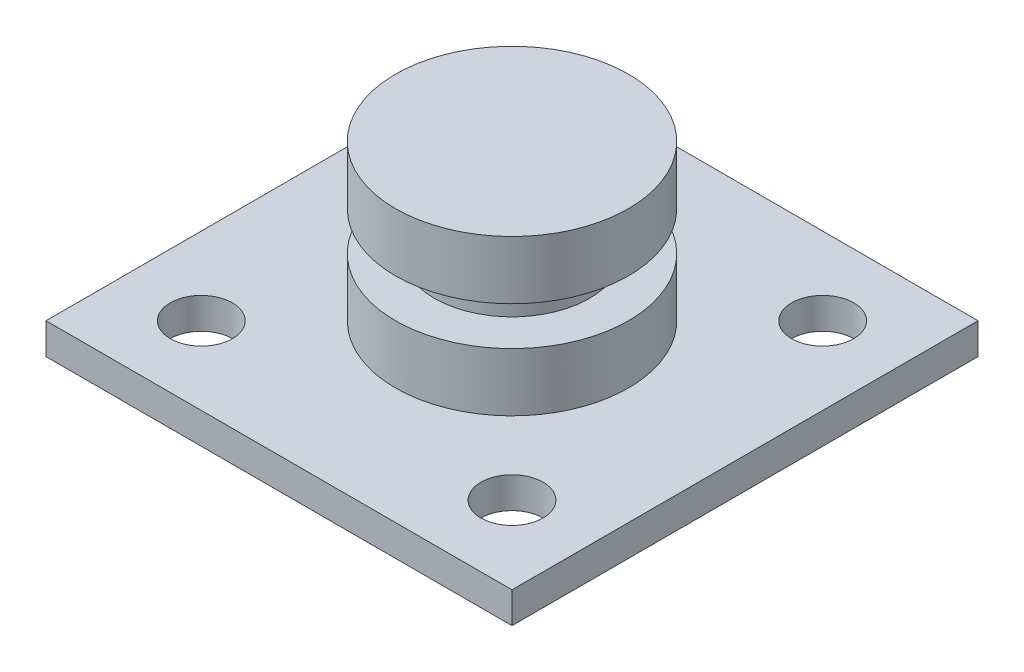
from build123d import *

# Parameters (mm, degrees)
SKETCH1_W           = 30
SKETCH1_H           = 30
BOSS_EXTRUDE1_DEPTH = 2
SKETCH3_R           = 2
CUT_EXTRUDE1_DEPTH  = 5
SKETCH2_R           = 7.5
BOSS_EXTRUDE2_DEPTH = 10
SKETCH4_W           = 5
SKETCH4_H           = 2.5


with BuildPart() as part:
    # Sketch1 → Boss-Extrude1 (new body)
    with BuildSketch(Plane(origin=(0, 0, 0), x_dir=(1, 0, 0), z_dir=(0, 1, 0))):
        Rectangle(SKETCH1_W, SKETCH1_H)
    extrude(amount=BOSS_EXTRUDE1_DEPTH)

    # Sketch3 → Cut-Extrude1 (cut)
    with BuildSketch(Plane(origin=(0, 2, 0), x_dir=(1, 0, 0), z_dir=(0, 1, 0))):
        with Locations((-10, 10)):
            Circle(SKETCH3_R)
        with Locations((10, 10)):
            Circle(SKETCH3_R)
        with Locations((10, -10)):
            Circle(SKETCH3_R)
        with Locations((-10, -10)):
            Circle(SKETCH3_R)
    extrude(amount=-CUT_EXTRUDE1_DEPTH, mode=Mode.SUBTRACT)

    # Sketch2 → Boss-Extrude2 (add)
    with BuildSketch(Plane(origin=(0, 2, 0), x_dir=(1, 0, 0), z_dir=(0, 1, 0))):
        Circle(SKETCH2_R)
    extrude(amount=BOSS_EXTRUDE2_DEPTH)

    # Sketch4 → Cut-Revolve1 (revolve, cut)
    with BuildSketch(Plane(origin=(0, 0, 0), x_dir=(0, 0, -1), z_dir=(1, 0, 0))):
        with Locations((-7.5, 7)):
            Rectangle(SKETCH4_W, SKETCH4_H)
    revolve(axis=Axis((0, 16.444012907, 0), (0, -1, 0)), mode=Mode.SUBTRACT)


solid = part.part
